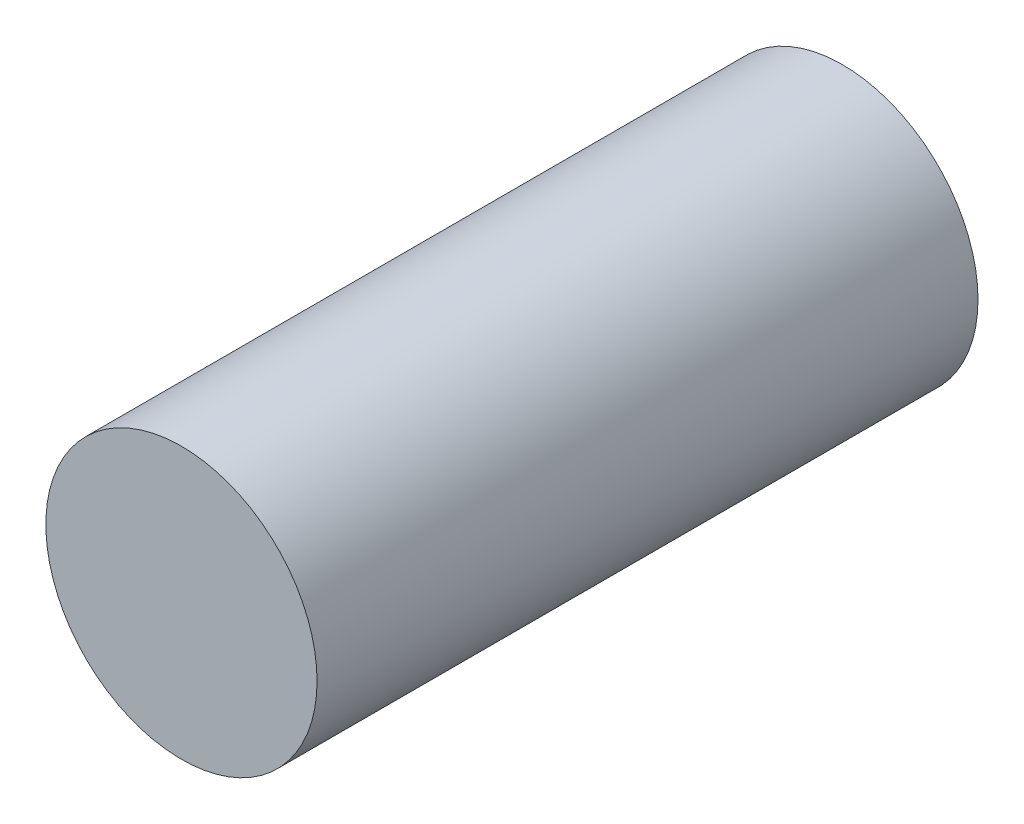
from build123d import *

# Parameters (mm, degrees)
SKETCH1_R           = 5.95
BOSS_EXTRUDE1_DEPTH = 29


with BuildPart() as part:
    # Sketch1 → Boss-Extrude1 (new body)
    with BuildSketch(Plane.XY):
        with Locations((-18.495917177, 12.939831384)):
            Circle(SKETCH1_R)
    extrude(amount=BOSS_EXTRUDE1_DEPTH)


solid = part.part
